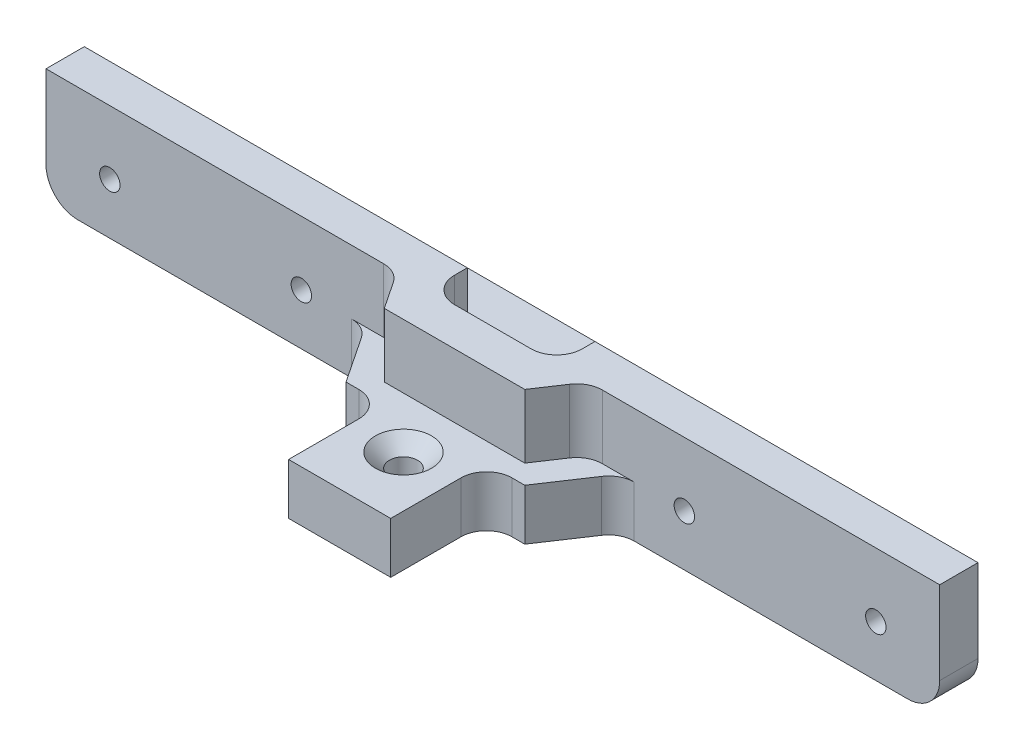
from build123d import *

# Parameters (mm, degrees)
BOSS_EXTRUDE1_DEPTH                          = 4
SKETCH2_W                                    = 70
SKETCH2_H                                    = 3
BOSS_EXTRUDE2_DEPTH                          = 5
CSK_FOR_M2_COUNTERSUNK_FLAT_HEAD_SCR_2_COUNT = 2
CSK_FOR_M2_COUNTERSUNK_FLAT_HEAD_SCR_2_PITCH = 10
SKETCH5_W                                    = 10
SKETCH5_H                                    = 3
CUT_EXTRUDE1_DEPTH                           = 5
FILLET1_R                                    = 2.5
M2_TAPPED_HOLE1_D                            = 1.6
M2_TAPPED_HOLE1_DEPTH                        = 3
BOSS_EXTRUDE3_DEPTH                          = 5
FILLET2_R                                    = 2


with BuildPart() as part:
    # Sketch1 → Boss-Extrude1 (new body)
    with BuildSketch(Plane(origin=(0, 0, 0), x_dir=(1, 0, 0), z_dir=(0, 1, 0))):
        Polygon((-4, 0), (4, 0), (4, 7.5), (7, 7.5), (10, 12), (35, 12), (35, 15), (10, 15), (10, 20), (-10, 20), (-10, 15), (-35, 15), (-35, 12), (-10, 12), (-7, 7.5), (-4, 7.5), align=None)
    extrude(amount=BOSS_EXTRUDE1_DEPTH)

    # Sketch2 → Boss-Extrude2 (add)
    with BuildSketch(Plane(origin=(0, 4, 0), x_dir=(1, 0, 0), z_dir=(0, 1, 0))):
        with Locations((0, 13.5)):
            Rectangle(SKETCH2_W, SKETCH2_H)
    extrude(amount=BOSS_EXTRUDE2_DEPTH)

    # Sketch4 → CSK for M2 Countersunk Flat Head Screw1 (revolve, cut)
    with BuildSketch(Plane(origin=(0, 4, -15), x_dir=(0, 0, 1), z_dir=(1, 0, 0))):
        Polygon((0, 0), (0, 4), (1.1, 4), (1.1, 1.1), (2.2, 0), align=None)
    csk_for_m2_countersunk_flat_head_screw1 = revolve(axis=Axis((0, 10.35, -15), (0, -1, 0)), mode=Mode.SUBTRACT)

    # CSK for M2 Countersunk Flat Head Scr 2: CSK for M2 Countersunk Flat Head Screw1 ×2
    with Locations(*[(0, 0, i * CSK_FOR_M2_COUNTERSUNK_FLAT_HEAD_SCR_2_PITCH) for i in range(1, CSK_FOR_M2_COUNTERSUNK_FLAT_HEAD_SCR_2_COUNT)]):
        add(csk_for_m2_countersunk_flat_head_screw1, mode=Mode.SUBTRACT)

    # Sketch5 → Cut-Extrude1 (cut)
    with BuildSketch(Plane(origin=(0, 9, 0), x_dir=(1, 0, 0), z_dir=(0, 1, 0))):
        with Locations((0, 13.5)):
            Rectangle(SKETCH5_W, SKETCH5_H)
    extrude(amount=-CUT_EXTRUDE1_DEPTH, mode=Mode.SUBTRACT)

    # Fillet1
    fillet1_edges = [part.edges().sort_by_distance(p)[0] for p in [
        (-35, 0, -13.5),
        (35, 0, -13.5),
    ]]
    fillet(fillet1_edges, radius=FILLET1_R)

    # M2 Tapped Hole1
    with Locations(Plane(origin=(0, 0, -15), x_dir=(-1, 0, 0), z_dir=(0, 0, -1))):
        with Locations((30, 4), (15, 4), (-15, 4), (-30, 4)):
            Hole(M2_TAPPED_HOLE1_D / 2, depth=M2_TAPPED_HOLE1_DEPTH)

    # Sketch9 → Boss-Extrude3 (add)
    with BuildSketch(Plane(origin=(0, 4, 0), x_dir=(1, 0, 0), z_dir=(0, 1, 0))):
        Polygon((-7.5, 12), (-5.5, 9), (5.5, 9), (7.5, 12), align=None)
    extrude(amount=BOSS_EXTRUDE3_DEPTH)

    # Fillet2
    fillet2_edges = [part.edges().sort_by_distance(p)[0] for p in [
        (7.5, 6.5, -12),
        (-7.5, 6.5, -12),
        (-4, 2, -7.5),
        (-10, 2, -12),
        (10, 2, -12),
        (4, 2, -7.5),
        (-5, 6.5, -12),
        (5, 6.5, -12),
    ]]
    fillet(fillet2_edges, radius=FILLET2_R)


solid = part.part
